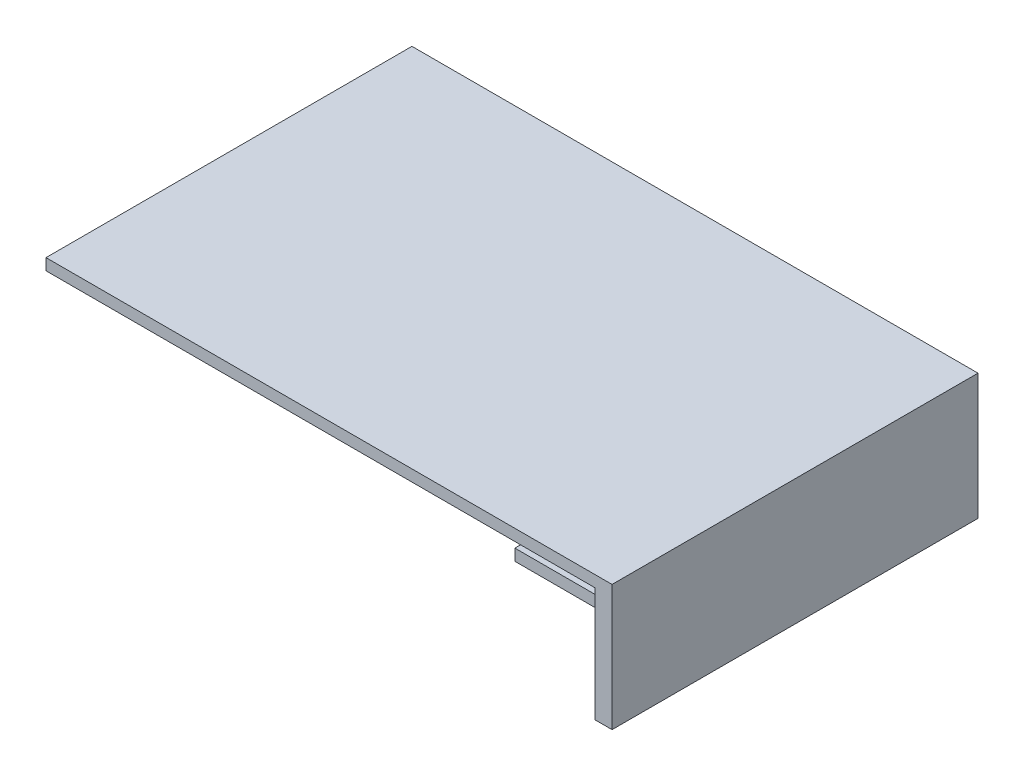
from build123d import *

# Parameters (mm, degrees)
SKETCH1_W           = 4.7625
SKETCH1_H           = 101.6
BOSS_EXTRUDE1_DEPTH = 34.925
SKETCH2_W           = 101.6
SKETCH2_H           = 3.175
BOSS_EXTRUDE2_DEPTH = 152.4
SKETCH2_4_W         = 1.5875
SKETCH2_4_H         = 3.175
BOSS_EXTRUDE3_DEPTH = 25.4


with BuildPart() as part:
    # Sketch1 → Boss-Extrude1 (new body)
    with BuildSketch(Plane(origin=(0, -30.757642186, 0), x_dir=(-1, 0, 0), z_dir=(0, -1, 0))):
        with Locations((-83.04427371, -7.755970668)):
            Rectangle(SKETCH1_W, SKETCH1_H)
    extrude(amount=-BOSS_EXTRUDE1_DEPTH)

    # Sketch2 → Boss-Extrude2 (add)
    with BuildSketch(Plane.ZY.offset(-80.66302371)):
        with Locations((7.755970668, 2.579857814)):
            Rectangle(SKETCH2_W, SKETCH2_H)
    extrude(amount=BOSS_EXTRUDE2_DEPTH)

    # Sketch2_4 → Boss-Extrude3 (add)
    with BuildSketch(Plane.ZY.offset(-80.66302371)):
        with Locations((-39.075279332, -5.357642186)):
            Rectangle(SKETCH2_4_W, SKETCH2_4_H)
        with Locations((54.587220668, -5.357642186)):
            Rectangle(SKETCH2_4_W, SKETCH2_4_H)
    extrude(amount=BOSS_EXTRUDE3_DEPTH)


solid = part.part
